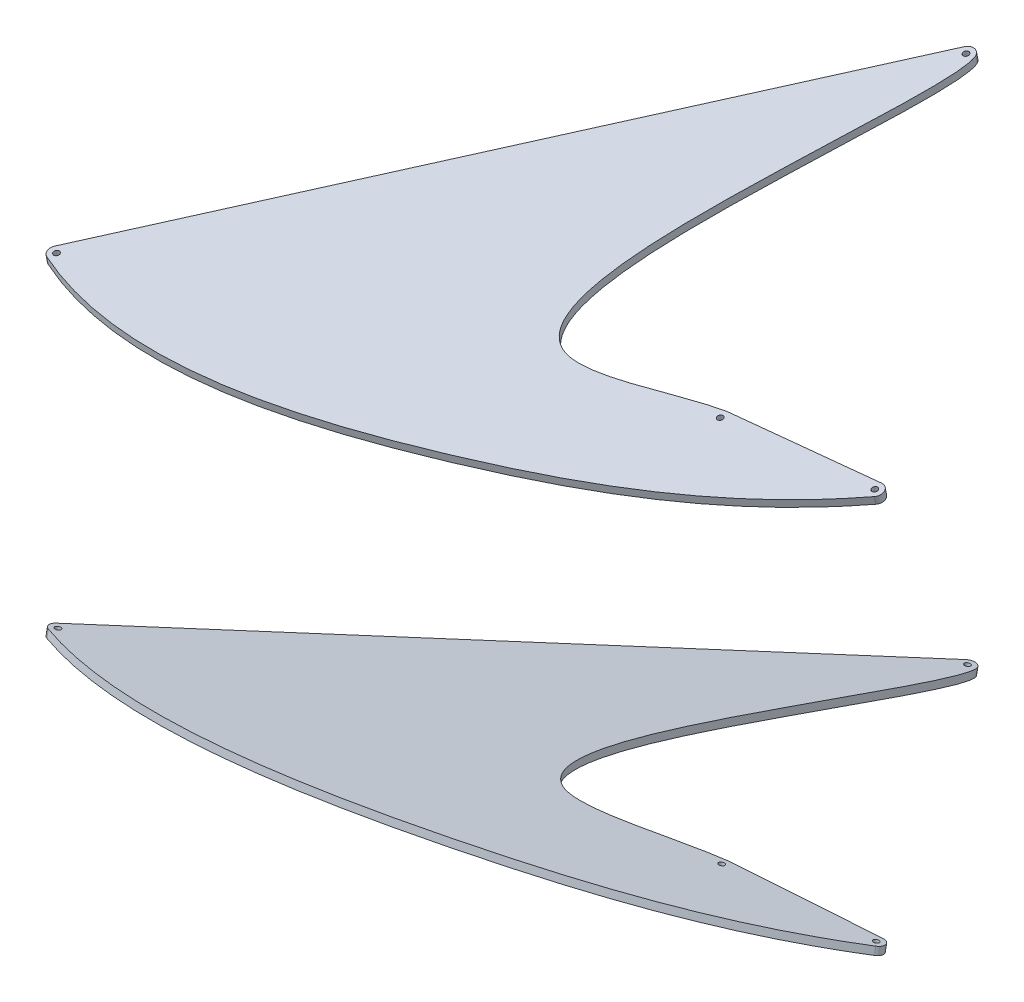
from build123d import *

# Parameters (mm, degrees)
SZKIC1_R                    = 3
SZKIC1_R_2                  = 2.999999996
DODANIE_WYCI_GNI_CIE1_DEPTH = 8


with BuildPart() as part:
    # Szkic1 → Dodanie-wyciągnięcie1 (new body)
    with BuildSketch(Plane(origin=(0, -365.945689178, 71.13263619), x_dir=(1, 0, 0), z_dir=(0, 0.981627183, -0.190808995))):
        with BuildLine():
            ThreePointArc((1640.281331001, -808.853368538), (1642.326429132, -800.05707281), (1634.871598877, -794.959745005))
            Line((1634.871598877, -794.959745005), (1633.418389297, -795.092840791))
            Line((1633.418389297, -795.092840791), (1483.1737317, -808.853368538))
            add(Edge.make_bspline(
                [(1483.1737317, -808.853368538), (1437.469754318, -816.5628016), (1275.879179559, -890.619951369), (1317.913749169, -619.983132718), (1370.507425365, -433.806229295), (1362.283628975, -415.546989785)],
                knots=[0, 0, 0, 0, 0.258279361, 0.641643028, 1, 1, 1, 1], degree=3))
            ThreePointArc((1362.283628975, -415.546989785), (1355.785767616, -410.872022391), (1348.49049843, -414.166953328))
            Line((1348.49049843, -414.166953328), (939.37128434, -984.072476035))
            ThreePointArc((939.37128434, -984.072476035), (938.177076077, -990.932618484), (942.811265429, -996.129923251))
            add(Edge.make_bspline(
                [(942.811265429, -996.129923251), (1065.430635851, -1046.869568532), (1335.806413784, -985.712102893), (1556.499884294, -885.756004267), (1640.281331001, -808.853368538)],
                knots=[0, 0, 0, 0, 0.548324659, 1, 1, 1, 1], degree=3))
        make_face()
        with Locations((945.87011042, -988.737801274)):
            Circle(SZKIC1_R, mode=Mode.SUBTRACT)
        with Locations((1483.903377602, -816.820025105)):
            Circle(SZKIC1_R, mode=Mode.SUBTRACT)
        with Locations((1634.871598877, -802.959745005)):
            Circle(SZKIC1_R_2, mode=Mode.SUBTRACT)
        with Locations((1354.98932451, -418.832278566)):
            Circle(SZKIC1_R, mode=Mode.SUBTRACT)
    extrude(amount=DODANIE_WYCI_GNI_CIE1_DEPTH)


with BuildPart() as body_2:
    # Lustro2: mirrored copy
    add(part.part.mirror(Plane.ZX))


solid = Compound([part.part, body_2.part])
